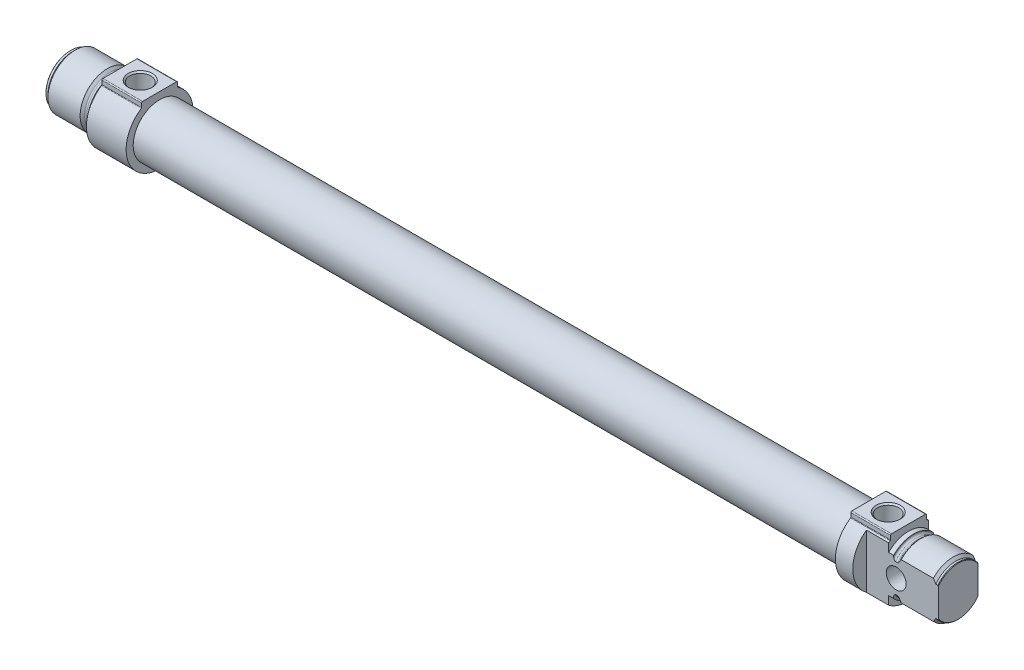
from build123d import *

# Parameters (mm, degrees)
BOSS_EXTRUDE1_DEPTH     = 16
SKETCH3_W               = 286
SKETCH3_H               = 10.65
BOSS_EXTRUDE2_DEPTH     = 16
CUT_EXTRUDE1_DEPTH      = 13.5
CUT_EXTRUDE1_DEPTH_BACK = 13.5
HOLE1_D                 = 8
HOLE2_D                 = 8.566
HOLE2_DEPTH             = 13.5
HOLE2_CSINK_D           = 9.728
HOLE2_CSINK_ANGLE       = 90
HOLE3_D                 = 8.566
HOLE3_DEPTH             = 16
HOLE3_CSINK_D           = 9.728
HOLE3_CSINK_ANGLE       = 90
HOLE3_TIP               = 2.472791203


with BuildPart() as part:
    # Sketch1 → Revolve1 (revolve)
    with BuildSketch(Plane.XY):
        with BuildLine():
            Line((0, 0), (0, 9.8))
            Line((0, 9.8), (0.2, 10))
            Line((0.2, 10), (1, 10))
            Line((1, 10), (2, 11))
            Line((2, 11), (14.95, 11))
            Line((14.95, 11), (15.865685425, 10.084314575))
            ThreePointArc((15.865685425, 10.084314575), (16.125224104, 9.910896374), (16.43137085, 9.85))
            Line((16.43137085, 9.85), (17.2, 9.85))
            ThreePointArc((17.2, 9.85), (17.765685425, 10.084314575), (18, 10.65))
            Line((18, 10.65), (18, 11))
            Line((18, 11), (20, 11))
            Line((20, 11), (20, 0))
            Line((20, 0), (0, 0))
        make_face()
    revolve(axis=Axis((20, 0, 0), (-1, 0, 0)))

    # Sketch2 → Boss-Extrude1 (add)
    with BuildSketch(Plane(origin=(20, 0, 0), x_dir=(0, 0, -1), z_dir=(1, 0, 0))):
        with BuildLine():
            Line((7.25, 11.551515052), (7.25, 13.1))
            ThreePointArc((7.25, 13.1), (7.132842712, 13.382842712), (6.85, 13.5))
            Line((6.85, 13.5), (-6.85, 13.5))
            ThreePointArc((-6.85, 13.5), (-7.132842712, 13.382842712), (-7.25, 13.1))
            Line((-7.25, 13.1), (-7.25, 11.551515052))
            ThreePointArc((-7.25, 11.551515052), (-7.286144803, 11.408754992), (-7.385869565, 11.30039516))
            ThreePointArc((-7.385869565, 11.30039516), (0, -13.5), (7.385869565, 11.30039516))
            ThreePointArc((7.385869565, 11.30039516), (7.286144803, 11.408754992), (7.25, 11.551515052))
        make_face()
    extrude(amount=BOSS_EXTRUDE1_DEPTH)

    # Sketch3 → Revolve2 (revolve)
    with BuildSketch(Plane.XY):
        with Locations((179, 5.325)):
            Rectangle(SKETCH3_W, SKETCH3_H)
    revolve(axis=Axis((322, 0, 0), (-1, 0, 0)))

    # Sketch4 → Boss-Extrude2 (add)
    with BuildSketch(Plane(origin=(322, 0, 0), x_dir=(0, 0, -1), z_dir=(1, 0, 0))):
        with BuildLine():
            Line((7.25, 11.551515052), (7.25, 13.1))
            ThreePointArc((7.25, 13.1), (7.132842712, 13.382842712), (6.85, 13.5))
            Line((6.85, 13.5), (-6.85, 13.5))
            ThreePointArc((-6.85, 13.5), (-7.132842712, 13.382842712), (-7.25, 13.1))
            Line((-7.25, 13.1), (-7.25, 11.551515052))
            ThreePointArc((-7.25, 11.551515052), (-7.286144803, 11.408754992), (-7.385869565, 11.30039516))
            ThreePointArc((-7.385869565, 11.30039516), (0, -13.5), (7.385869565, 11.30039516))
            ThreePointArc((7.385869565, 11.30039516), (7.286144803, 11.408754992), (7.25, 11.551515052))
        make_face()
    extrude(amount=BOSS_EXTRUDE2_DEPTH)

    # Sketch5 → Revolve3 (revolve)
    with BuildSketch(Plane.XY):
        with BuildLine():
            Line((338, 0), (338, 11))
            Line((338, 11), (340, 11))
            Line((340, 11), (340, 10.65))
            ThreePointArc((340, 10.65), (340.234314575, 10.084314575), (340.8, 9.85))
            Line((340.8, 9.85), (341.56862915, 9.85))
            ThreePointArc((341.56862915, 9.85), (341.874775896, 9.910896374), (342.134314575, 10.084314575))
            Line((342.134314575, 10.084314575), (343.05, 11))
            Line((343.05, 11), (356, 11))
            Line((356, 11), (357, 10))
            Line((357, 10), (357.8, 10))
            Line((357.8, 10), (358, 9.8))
            Line((358, 9.8), (358, 0))
            Line((358, 0), (338, 0))
        make_face()
    revolve(axis=Axis((358, 0, 0), (-1, 0, 0)))

    # Sketch6 → Cut-Extrude1 (cut, two sides: drawn at the far end of the back side and taken through both)
    with BuildSketch(Plane(origin=(0, 0, 0), x_dir=(1, 0, 0), z_dir=(0, 1, 0)).offset(-CUT_EXTRUDE1_DEPTH_BACK)):
        Polygon((329, 24), (329, 8), (358, 8), (358, -8), (329, -8), (329, -24), (374, -24), (374, 24), align=None)
    extrude(amount=CUT_EXTRUDE1_DEPTH + CUT_EXTRUDE1_DEPTH_BACK, mode=Mode.SUBTRACT)

    # Hole1 (through all)
    with Locations(Plane(origin=(0, 0, -8), x_dir=(-1, 0, 0), z_dir=(0, 0, -1))):
        with Locations((-341, 0)):
            Hole(HOLE1_D / 2)

    # Hole2
    with Locations(Plane(origin=(0, 13.5, 0), x_dir=(1, 0, 0), z_dir=(0, 1, 0))):
        with Locations((28.2, 0)):
            CounterSinkHole(HOLE2_D / 2, HOLE2_CSINK_D / 2, depth=HOLE2_DEPTH, counter_sink_angle=HOLE2_CSINK_ANGLE)

    # Hole3
    with Locations(Plane(origin=(0, 13.5, 0), x_dir=(1, 0, 0), z_dir=(0, 1, 0))):
        with Locations((329.8, 0)):
            CounterSinkHole(HOLE3_D / 2, HOLE3_CSINK_D / 2, depth=HOLE3_DEPTH, counter_sink_angle=HOLE3_CSINK_ANGLE)
            with Locations((0, 0, -(HOLE3_DEPTH + HOLE3_TIP / 2))):  # 120° drill point
                Cone(0, HOLE3_D / 2, HOLE3_TIP, mode=Mode.SUBTRACT)

    # Sketch13 → Cut-Revolve1 (revolve, cut)
    with BuildSketch(Plane.XY):
        Polygon((-4, 0), (-4, 4), (50.3, 4), (50.3, 10), (305.3, 10), (305.3, 0), align=None)
    revolve(axis=Axis((305.3, 0, 0), (-1, 0, 0)), mode=Mode.SUBTRACT)


solid = part.part
